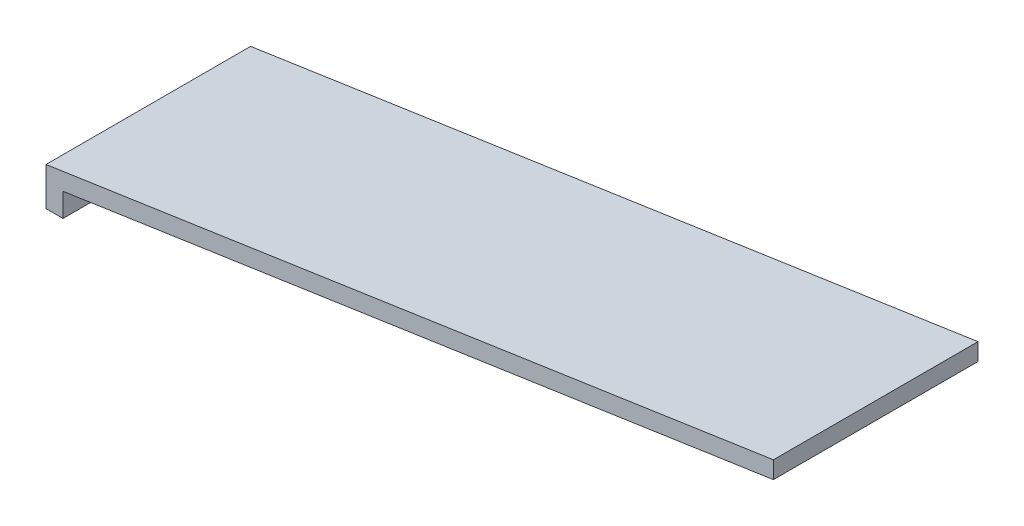
from build123d import *

# Parameters (mm, degrees)
BOSS_EXTRUDE1_DEPTH = 3.6


with BuildPart() as part:
    # Sketch1 → Boss-Extrude1 (new body)
    with BuildSketch(Plane.XY.offset(2.15)):
        Polygon((-0.8, 0.392938217), (-0.8, -0.280061783), (-0.5, -0.280061783), (-0.5, 0.134182422), (12, 1.989651172), (12, 2.292938217), align=None)
    extrude(amount=-BOSS_EXTRUDE1_DEPTH)


solid = part.part
